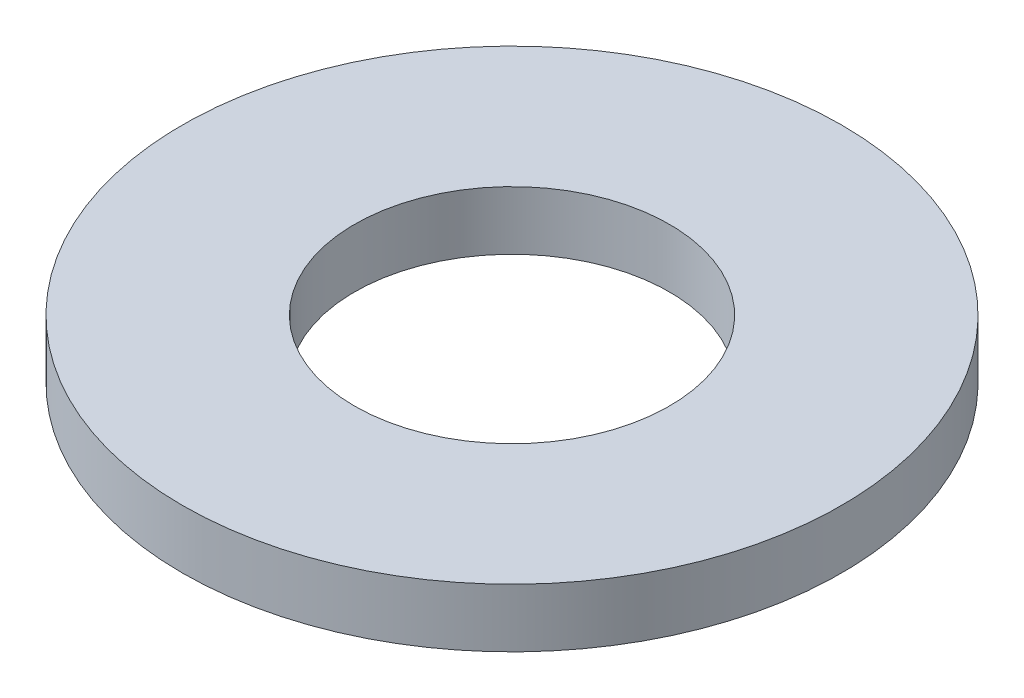
from build123d import *

# Parameters (mm, degrees)
SKETCH1_R      = 4.5
SKETCH1_R_2    = 2.15
EXTRUDE1_DEPTH = 0.8


with BuildPart() as part:
    # Sketch1 → Extrude1 (new body)
    with BuildSketch(Plane(origin=(0, 0, 0), x_dir=(1, 0, 0), z_dir=(0, 1, 0))):
        with Locations(Location((0, 0, 0), (0, 0, 270))):  # turned: the seam where the file's is
            Circle(SKETCH1_R)
        with Locations(Location((0, 0, 0), (0, 0, 270))):  # turned: the seam where the file's is
            Circle(SKETCH1_R_2, mode=Mode.SUBTRACT)
    extrude(amount=EXTRUDE1_DEPTH)


solid = part.part
